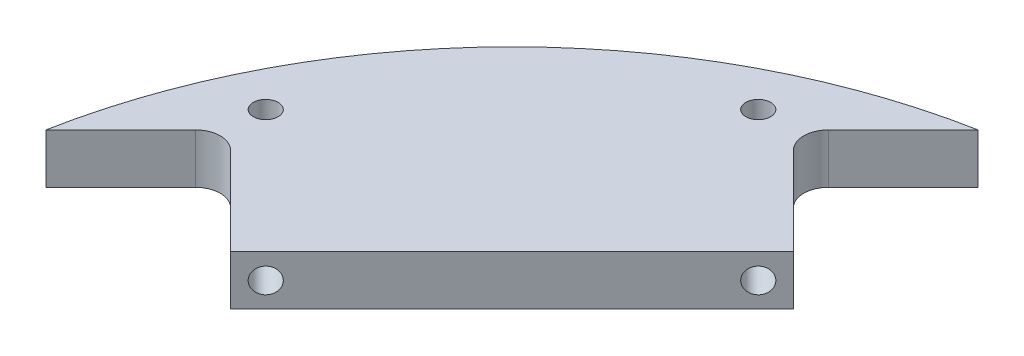
from build123d import *

# Parameters (mm, degrees)
CRADLE_DEPTH                                  = 12.7
SKETCH1_R                                     = 3.175
CUT_EXTRUDE1_DEPTH                            = 12.7
QUARTER_INCH_FILLETS_R                        = 6.35
SKETCH4_R                                     = 3.175
F_0_25_28_DIAMETER_TAPPED_HOLES_FOR_LID_DEPTH = 12.7


with BuildPart() as part:
    # Base → Cradle (new body)
    with BuildSketch(Plane(origin=(0, 0, 0), x_dir=(1, 0, 0), z_dir=(0, 1, 0))):
        with BuildLine():
            Line((-27.68192265, 146.634960986), (-51.237417334, 123.079466302))
            Line((-51.237417334, 123.079466302), (-24.296648971, 96.138697939))
            Line((-24.296648971, 96.138697939), (-96.138697939, 24.296648971))
            Line((-96.138697939, 24.296648971), (-123.079466302, 51.237417334))
            Line((-123.079466302, 51.237417334), (-146.634960986, 27.68192265))
            ThreePointArc((-146.634960986, 27.68192265), (-105.518009423, 105.518009423), (-27.68192265, 146.634960986))
        make_face()
    extrude(amount=CRADLE_DEPTH)

    # Sketch1 → Cut-Extrude1 (cut)
    with BuildSketch(Plane(origin=(0, 12.7, 0), x_dir=(1, 0, 0), z_dir=(0, 1, 0))):
        with Locations((-60.217673455, 123.079466302)):
            Circle(SKETCH1_R)
        with Locations((-123.079466302, 60.217673455)):
            Circle(SKETCH1_R)
    extrude(amount=-CUT_EXTRUDE1_DEPTH, mode=Mode.SUBTRACT)

    # Quarter Inch Fillets
    quarter_inch_fillets_edges = [part.edges().sort_by_distance(p)[0] for p in [
        (-123.079466302, 6.35, -51.237417334),
        (-51.237417334, 6.35, -123.079466302),
    ]]
    fillet(quarter_inch_fillets_edges, radius=QUARTER_INCH_FILLETS_R)

    # Sketch4 → 0.25"-28 Diameter Tapped Holes for Lid (cut)
    with BuildSketch(Plane(origin=(-60.217673455, 0, -60.217673455), x_dir=(0.707106781, 0, -0.707106781), z_dir=(0.707106781, 0, 0.707106781))):
        with Locations((44.45, 6.35)):
            Circle(SKETCH4_R)
        with Locations((-44.45, 6.35)):
            Circle(SKETCH4_R)
    extrude(amount=-F_0_25_28_DIAMETER_TAPPED_HOLES_FOR_LID_DEPTH, mode=Mode.SUBTRACT)


solid = part.part
